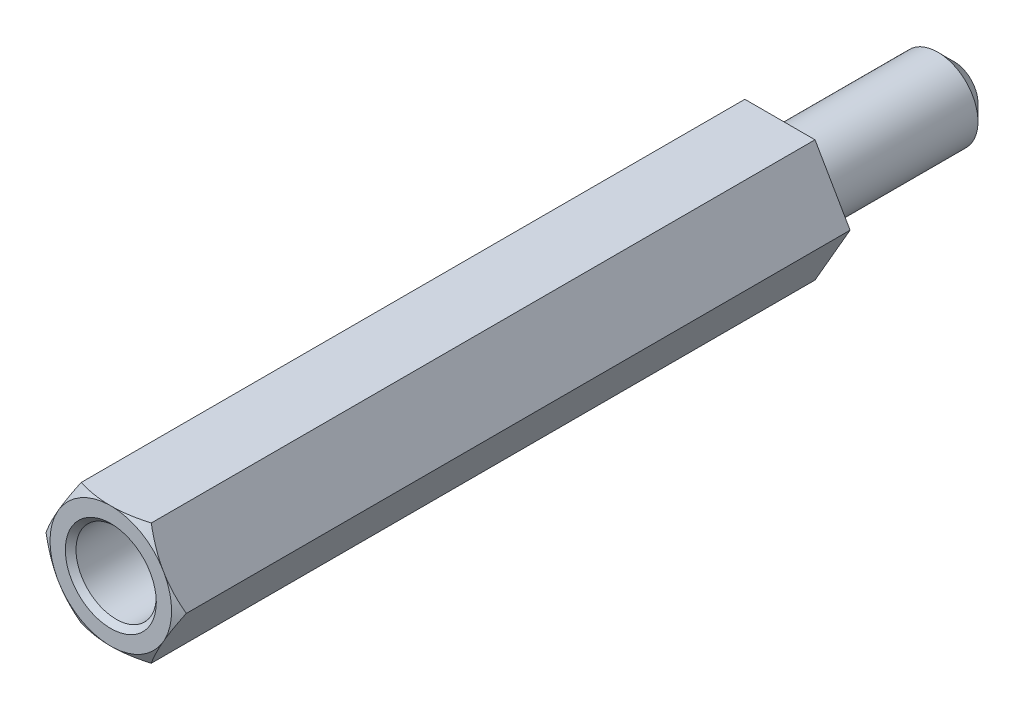
from build123d import *

# Parameters (mm, degrees)
BOSS_EXTRUDE1_DEPTH     = 25
SKETCH2_R               = 1.5
CUT_EXTRUDE1_DEPTH      = 1
CUT_EXTRUDE1_DEPTH_BACK = 12
CHAMFER1_SIZE           = 0.2
SKETCH4_R               = 1.5
BOSS_EXTRUDE2_DEPTH     = 6.5
CHAMFER2_SIZE           = 0.6


with BuildPart() as part:
    # Sketch1 → Boss-Extrude1 (new body)
    with BuildSketch(Plane.XY):
        Polygon((2.621170222, 0), (1.310585111, 2.27), (-1.310585111, 2.27), (-2.621170222, 0), (-1.310585111, -2.27), (1.310585111, -2.27), align=None)
    extrude(amount=BOSS_EXTRUDE1_DEPTH)

    # Sketch2 → Cut-Extrude1 (cut, two sides)
    with BuildSketch(Plane.XY.offset(25)) as cut_extrude1_sk:
        Circle(SKETCH2_R)
    extrude(amount=CUT_EXTRUDE1_DEPTH, mode=Mode.SUBTRACT)
    extrude(cut_extrude1_sk.sketch, amount=-CUT_EXTRUDE1_DEPTH_BACK, mode=Mode.SUBTRACT)

    # Sketch3 → Cut-Revolve1 (revolve, cut)
    with BuildSketch(Plane(origin=(0, 0, 0), x_dir=(1, 0, 0), z_dir=(0, 1, 0))):
        Polygon((-2.621170222, -25), (-2.271170222, -25), (-2.621170222, -24.8), align=None)
    revolve(axis=Axis((0, 0, 13), (0, 0, 1)), mode=Mode.SUBTRACT)

    # Chamfer1
    chamfer1_edges = [part.edges().sort_by_distance(p)[0] for p in [
        (-1.5, 0, 25),
    ]]
    chamfer(chamfer1_edges, length=CHAMFER1_SIZE)

    # Sketch4 → Boss-Extrude2 (add)
    with BuildSketch(Plane(origin=(0, 0, 0), x_dir=(-1, 0, 0), z_dir=(0, 0, -1))):
        Circle(SKETCH4_R)
    extrude(amount=BOSS_EXTRUDE2_DEPTH)

    # Chamfer2
    chamfer2_edges = [part.edges().sort_by_distance(p)[0] for p in [
        (1.5, 0, -6.5),
    ]]
    chamfer(chamfer2_edges, length=CHAMFER2_SIZE)


solid = part.part
